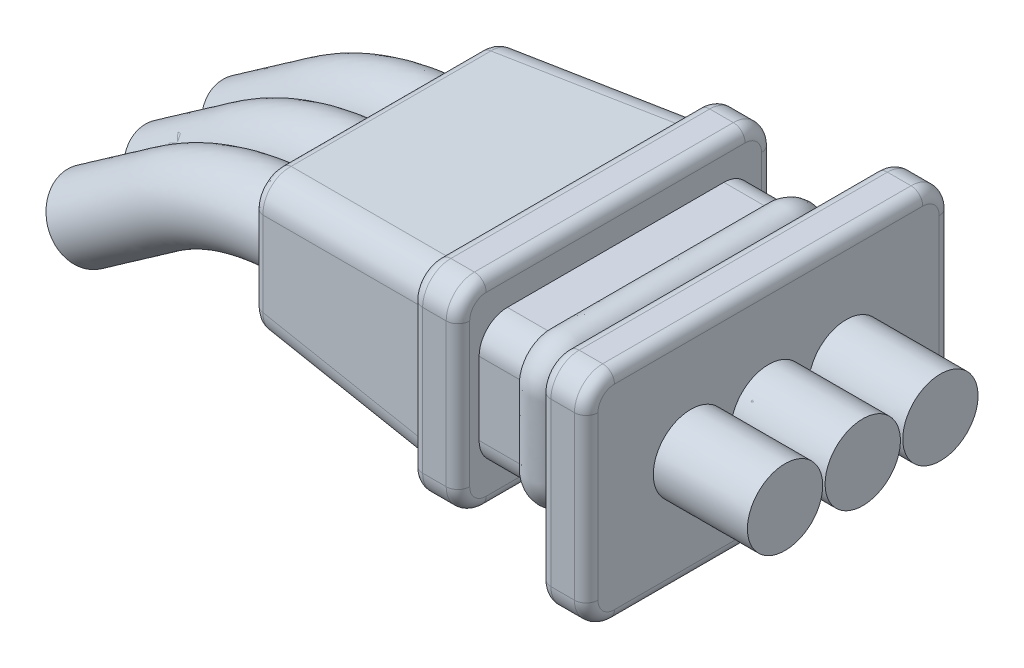
from build123d import *

# Parameters (mm, degrees)
SKETCH1_W            = 7.75
SKETCH1_H            = 4.65
BOSS_EXTRUDE1_DEPTH  = 1
SKETCH2_W            = 5.8
SKETCH2_H            = 2.75
BOSS_EXTRUDE2_DEPTH  = 2.25
SKETCH3_W            = 6.7
SKETCH3_H            = 4.25
BOSS_EXTRUDE3_DEPTH  = 1
SKETCH4_W            = 6.1
SKETCH4_H            = 3.65
BOSS_EXTRUDE4_DEPTH  = 4
BOSS_EXTRUDE4_TAPER  = 5
FILLET1_R            = 0.6
FILLET2_R            = 0.25
CUT_EXTRUDE6_DEPTH   = 9.25
SWEEP3_PROFILE_R     = 0.8
LPATTERN1_COUNT      = 2
LPATTERN1_PITCH      = 1.65
LPATTERN1_COUNT_DIR2 = 2
LPATTERN1_PITCH_DIR2 = 1.65


with BuildPart() as part:
    # Sketch1 → Boss-Extrude1 (new body)
    with BuildSketch(Plane(origin=(0, 0, 0), x_dir=(0, 0, -1), z_dir=(1, 0, 0))):
        Rectangle(SKETCH1_W, SKETCH1_H)
    extrude(amount=BOSS_EXTRUDE1_DEPTH)

    # Sketch2 → Boss-Extrude2 (add)
    with BuildSketch(Plane.ZY):
        Rectangle(SKETCH2_W, SKETCH2_H)
    extrude(amount=BOSS_EXTRUDE2_DEPTH)

    # Sketch3 → Boss-Extrude3 (add)
    with BuildSketch(Plane.ZY.offset(2.25)):
        Rectangle(SKETCH3_W, SKETCH3_H)
    extrude(amount=BOSS_EXTRUDE3_DEPTH)

    # Sketch4 → Boss-Extrude4 (add)
    with BuildSketch(Plane.ZY.offset(3.25)):
        Rectangle(SKETCH4_W, SKETCH4_H)
    extrude(amount=BOSS_EXTRUDE4_DEPTH, taper=BOSS_EXTRUDE4_TAPER)

    # Fillet1
    fillet1_edges = [part.edges().sort_by_distance(p)[0] for p in [
        (-1.125, 1.375, -2.9),
        (-1.125, -1.375, -2.9),
        (-1.125, -1.375, 2.9),
        (-1.125, 1.375, 2.9),
        (-2.75, 2.125, -3.35),
        (-2.75, -2.125, -3.35),
        (-2.75, -2.125, 3.35),
        (-2.75, 2.125, 3.35),
        (-5.25, 1.650022673, -2.875022673),
        (-5.25, -1.650022673, -2.875022673),
        (-5.25, -1.650022673, 2.875022673),
        (-5.25, 1.650022673, 2.875022673),
        (0.5, -2.325, -3.875),
        (0.5, -2.325, 3.875),
        (0.5, 2.325, 3.875),
        (0.5, 2.325, -3.875),
    ]]
    fillet(fillet1_edges, radius=FILLET1_R)

    # Sweep2: sweep along a path in Sketch7
    with BuildLine(Plane.ZY) as sweep2_path:
        Line((-2.3, -1.375), (2.3, -1.375))
        ThreePointArc((2.3, -1.375), (2.724264069, -1.199264069), (2.9, -0.775))
        Line((2.9, -0.775), (2.9, 0.775))
        ThreePointArc((2.9, 0.775), (2.724264069, 1.199264069), (2.3, 1.375))
        Line((2.3, 1.375), (-2.3, 1.375))
        ThreePointArc((-2.3, 1.375), (-2.724264069, 1.199264069), (-2.9, 0.775))
        Line((-2.9, 0.775), (-2.9, -0.775))
        ThreePointArc((-2.9, -0.775), (-2.724264069, -1.199264069), (-2.3, -1.375))
    # Sketch5 → Sweep2 (sweep)
    with BuildSketch(Plane(origin=(0, 0, 0), x_dir=(1, 0, 0), z_dir=(0, 1, 0))):
        with BuildLine():
            Line((-0.625, 2.9), (-1.375, 2.9))
            ThreePointArc((-1.375, 2.9), (-1, 3.116506351), (-0.625, 2.9))
        make_face()
    sweep(path=sweep2_path.line)

    # Fillet2
    fillet2_edges = [part.edges().sort_by_distance(p)[0] for p in [
        (0, 2.325, 0),
        (1, 2.325, 0),
        (0, 0, -3.875),
        (0, -2.325, 0),
        (0, 0, 3.875),
        (0, 2.149264069, 3.699264069),
        (0, -2.149264069, 3.699264069),
        (0, -2.149264069, -3.699264069),
        (0, 2.149264069, -3.699264069),
        (1, 0, -3.875),
        (1, 0, 3.875),
        (1, -2.325, 0),
        (1, 2.149264069, 3.699264069),
        (1, -2.149264069, 3.699264069),
        (1, -2.149264069, -3.699264069),
        (1, 2.149264069, -3.699264069),
        (-2.25, 0, -3.35),
        (-3.25, 0, -3.35),
        (-2.25, 2.125, 0),
        (-2.25, 0, 3.35),
        (-2.25, -2.125, 0),
        (-2.25, 1.949264069, 3.174264069),
        (-2.25, -1.949264069, 3.174264069),
        (-2.25, -1.949264069, -3.174264069),
        (-2.25, 1.949264069, -3.174264069),
        (-3.25, 2.125, 0),
        (-3.25, -2.125, 0),
        (-3.25, 0, 3.35),
        (-3.25, 1.949264069, 3.174264069),
        (-3.25, -1.949264069, 3.174264069),
        (-3.25, -1.949264069, -3.174264069),
        (-3.25, 1.949264069, -3.174264069),
        (-7.25, -1.475045346, 0),
        (-7.25, 0, -2.700045346),
        (-7.25, 0, 2.700045346),
        (-7.25, 1.475045346, 0),
        (-7.25, 1.300252666, 2.52525255),
        (-7.25, 1.30025255, -2.525252666),
        (-7.25, -1.300252666, 2.52525255),
        (-7.25, -1.300252666, -2.52525255),
    ]]
    fillet(fillet2_edges, radius=FILLET2_R)

    # Sketch15 → Cut-Extrude6 (cut, through all)
    with BuildSketch(Plane.ZY.offset(7.25)):
        with BuildLine():
            Line((-0.854701314, 0.25), (-0.795298686, 0.25))
            ThreePointArc((-0.795298686, 0.25), (-0.766858863, 0.258876084), (-0.74851641, 0.282352941))
            ThreePointArc((-0.74851641, 0.282352941), (0, 0.8), (0.74851641, 0.282352941))
            ThreePointArc((0.74851641, 0.282352941), (0.766858863, 0.258876084), (0.795298686, 0.25))
            Line((0.795298686, 0.25), (0.854701314, 0.25))
            ThreePointArc((0.854701314, 0.25), (0.883141137, 0.258876084), (0.90148359, 0.282352941))
            ThreePointArc((0.90148359, 0.282352941), (2.45, 0), (0.90148359, -0.282352941))
            ThreePointArc((0.90148359, -0.282352941), (0.883141137, -0.258876084), (0.854701314, -0.25))
            Line((0.854701314, -0.25), (0.795298686, -0.25))
            ThreePointArc((0.795298686, -0.25), (0.766858863, -0.258876084), (0.74851641, -0.282352941))
            ThreePointArc((0.74851641, -0.282352941), (0, -0.8), (-0.74851641, -0.282352941))
            ThreePointArc((-0.74851641, -0.282352941), (-0.766858863, -0.258876084), (-0.795298686, -0.25))
            Line((-0.795298686, -0.25), (-0.854701314, -0.25))
            ThreePointArc((-0.854701314, -0.25), (-0.883141137, -0.258876084), (-0.90148359, -0.282352941))
            ThreePointArc((-0.90148359, -0.282352941), (-2.45, 0), (-0.90148359, 0.282352941))
            ThreePointArc((-0.90148359, 0.282352941), (-0.883141137, 0.258876084), (-0.854701314, 0.25))
        make_face()
    extrude(amount=-CUT_EXTRUDE6_DEPTH, mode=Mode.SUBTRACT)


with BuildPart() as body_2:
    # Sweep3: sweep along a path in Sketch10
    with BuildLine(Plane.XY) as sweep3_path:
        Line((-11.779692326, -2.051392651), (-10.141388237, -0.904239779))
        ThreePointArc((-10.141388237, -0.904239779), (-8.777035053, -0.231415246), (-7.273506056, 0))
        Line((-7.273506056, 0), (1, 0))
        Line((1, 0), (3, 0))
    # Sweep3 profile (on start of the path) → Sweep3 (sweep)
    with BuildSketch(Plane(origin=(-11.779692326, -2.051392651, 0), x_dir=(-0.573576436, 0.819152044, 0), z_dir=(0.819152044, 0.573576436, 0))):
        Circle(SWEEP3_PROFILE_R)
    sweep3 = sweep(path=sweep3_path.line)


with BuildPart() as lpattern1_1:
    # LPattern1: Sweep3 2 × 2
    with Locations(*[Vector(0, 0, 1) * (i * LPATTERN1_PITCH) + Vector(0, 0, -1) * (j * LPATTERN1_PITCH_DIR2) for i in range(LPATTERN1_COUNT) for j in range(LPATTERN1_COUNT_DIR2) if (i, j) != (0, 0)]):
        add(sweep3)


solid = Compound([part.part, body_2.part, lpattern1_1.part])
